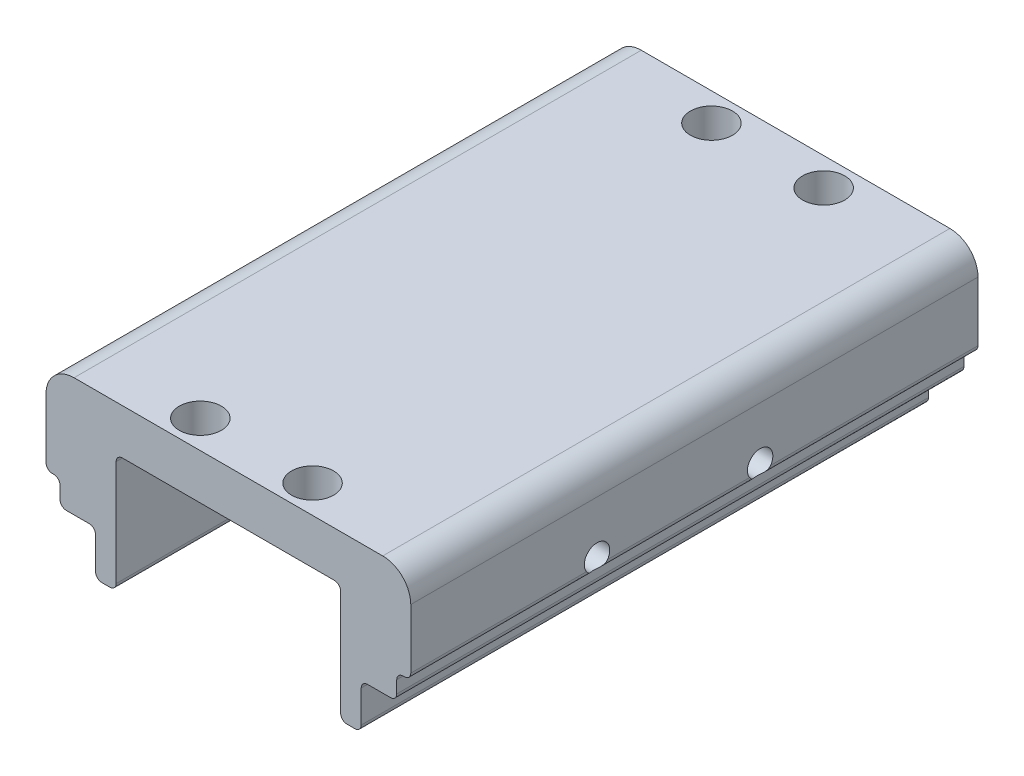
from build123d import *

# Parameters (mm, degrees)
BOSS_EXTRUDE1_DEPTH = 513.461
SKETCH2_R           = 19.05
CUT_EXTRUDE1_DEPTH  = 31.75
SKETCH3_R           = 3.2258
CUT_EXTRUDE2_DEPTH  = 31.75
SKETCH4_R           = 11.500000003
CUT_EXTRUDE3_DEPTH  = 499.872


with BuildPart() as part:
    # Sketch1 → Boss-Extrude1 (new body)
    with BuildSketch(Plane.XY):
        with BuildLine():
            ThreePointArc((-165.1, 5.715), (-163.426115254, 1.673884746), (-159.385, 0))
            Line((-159.385, 0), (-158.115, 0))
            ThreePointArc((-158.115, 0), (-154.073884746, -1.673884746), (-152.4, -5.715))
            Line((-152.4, -5.715), (-152.4, -16.91))
            ThreePointArc((-152.4, -16.91), (-150.726115254, -20.951115254), (-146.685, -22.625))
            Line((-146.685, -22.625), (-125.96, -22.625))
            ThreePointArc((-125.96, -22.625), (-121.918884746, -24.298884746), (-120.245, -28.34))
            Line((-120.245, -28.34), (-120.245, -57.40750012))
            ThreePointArc((-120.245, -57.40750012), (-118.571115254, -61.448615374), (-114.53, -63.12250012))
            Line((-114.53, -63.12250012), (-107.315, -63.12250012))
            ThreePointArc((-107.315, -63.12250012), (-103.273884746, -61.448615374), (-101.6, -57.40750012))
            Line((-101.6, -57.40750012), (-101.6, 0))
            Line((-101.6, 0), (-101.6, 38.17350945))
            ThreePointArc((-101.6, 38.17350945), (-99.926115254, 42.214624704), (-95.885, 43.88850945))
            Line((-95.885, 43.88850945), (95.885, 43.88850945))
            ThreePointArc((95.885, 43.88850945), (99.926115254, 42.214624704), (101.6, 38.17350945))
            Line((101.6, 38.17350945), (101.6, 0))
            Line((101.6, 0), (101.6, -57.40750012))
            ThreePointArc((101.6, -57.40750012), (103.273884746, -61.448615374), (107.315, -63.12250012))
            Line((107.315, -63.12250012), (114.53, -63.12250012))
            ThreePointArc((114.53, -63.12250012), (118.571115254, -61.448615374), (120.245, -57.40750012))
            Line((120.245, -57.40750012), (120.245, -28.34))
            ThreePointArc((120.245, -28.34), (121.918884746, -24.298884746), (125.96, -22.625))
            Line((125.96, -22.625), (146.685, -22.625))
            ThreePointArc((146.685, -22.625), (150.726115254, -20.951115254), (152.4, -16.91))
            Line((152.4, -16.91), (152.4, -5.715))
            ThreePointArc((152.4, -5.715), (154.073884746, -1.673884746), (158.115, 0))
            Line((158.115, 0), (159.385, 0))
            ThreePointArc((159.385, 0), (163.426115254, 1.673884746), (165.1, 5.715))
            Line((165.1, 5.715), (165.1, 59.52))
            ThreePointArc((165.1, 59.52), (157.660512242, 77.480512242), (139.7, 84.92))
            Line((139.7, 84.92), (-139.7, 84.92))
            ThreePointArc((-139.7, 84.92), (-157.660512242, 77.480512242), (-165.1, 59.52))
            Line((-165.1, 59.52), (-165.1, 5.715))
        make_face()
    extrude(amount=BOSS_EXTRUDE1_DEPTH)

    # Sketch2 → Cut-Extrude1 (cut)
    with BuildSketch(Plane(origin=(0, 84.92, 0), x_dir=(1, 0, 0), z_dir=(0, 1, 0))):
        with Locations((-50.8, -25.4)):
            Circle(SKETCH2_R)
        with Locations((50.8, -25.4)):
            Circle(SKETCH2_R)
        with Locations((50.8, -488.061)):
            Circle(SKETCH2_R)
        with Locations((-50.8, -488.061)):
            Circle(SKETCH2_R)
    extrude(amount=-CUT_EXTRUDE1_DEPTH, mode=Mode.SUBTRACT)

    # Sketch3 → Cut-Extrude2 (cut)
    with BuildSketch(Plane(origin=(0, 53.17, 0), x_dir=(1, 0, 0), z_dir=(0, 1, 0))):
        with Locations((-50.8, -25.4)):
            Circle(SKETCH3_R)
        with Locations((50.8, -25.4)):
            Circle(SKETCH3_R)
        with Locations((50.8, -488.061)):
            Circle(SKETCH3_R)
        with Locations((-50.8, -488.061)):
            Circle(SKETCH3_R)
    extrude(amount=-CUT_EXTRUDE2_DEPTH, mode=Mode.SUBTRACT)

    # Sketch4 → Cut-Extrude3 (cut)
    with BuildSketch(Plane.ZY.offset(165.1)):
        with Locations((344.866041788, 12.13850945)):
            Circle(SKETCH4_R)
        with Locations((197.228541788, 12.13850945)):
            Circle(SKETCH4_R)
    extrude(amount=-CUT_EXTRUDE3_DEPTH, mode=Mode.SUBTRACT)


solid = part.part
